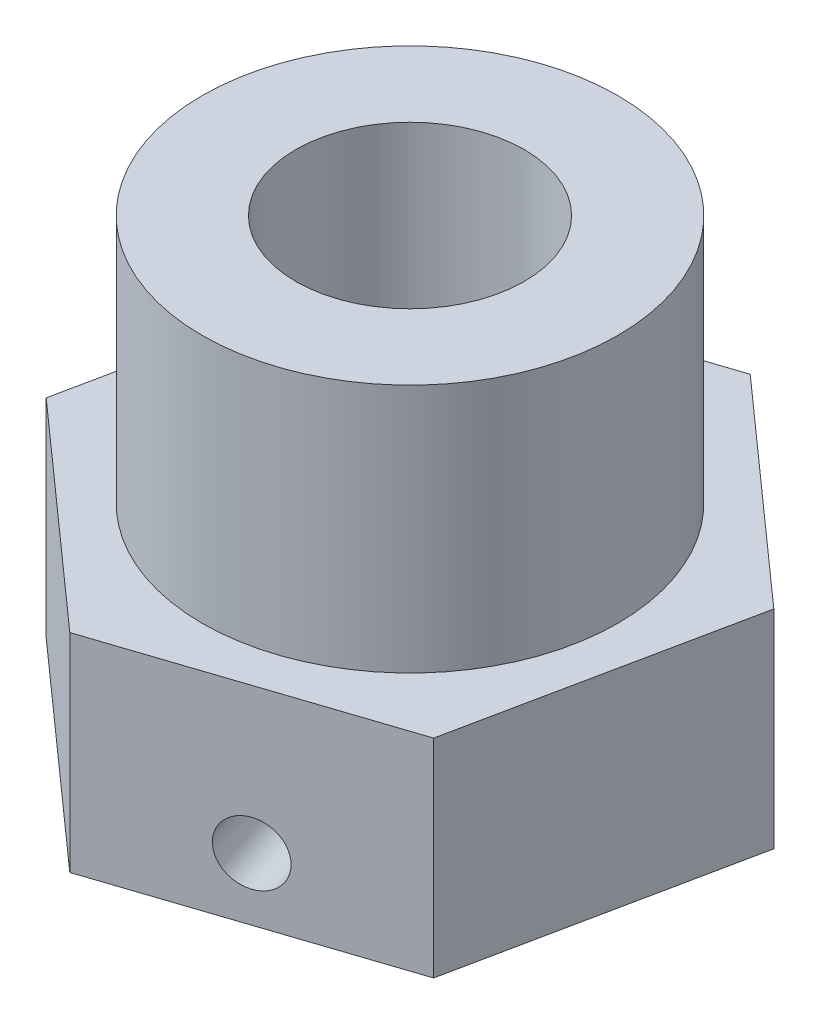
from build123d import *

# Parameters (mm, degrees)
CROQUIS1_R              = 2.75
SALIENTE_EXTRUIR1_DEPTH = 5
CROQUIS3_R              = 5
CROQUIS3_R_2            = 2.75
SALIENTE_EXTRUIR2_DEPTH = 6
CROQUIS2_R              = 0.75
CORTAR_EXTRUIR1_DEPTH   = 15.508806178


with BuildPart() as part:
    # Croquis1 → Saliente-Extruir1 (new body)
    with BuildSketch(Plane(origin=(0, 0, 0), x_dir=(1, 0, 0), z_dir=(0, 1, 0))):
        Polygon((1.401704423, 6.784926286), (-5.175066315, 4.606374782), (-6.576770738, -2.178551504), (-1.401704423, -6.784926286), (5.175066315, -4.606374782), (6.576770738, 2.178551504), align=None)
        Circle(CROQUIS1_R, mode=Mode.SUBTRACT)
    extrude(amount=SALIENTE_EXTRUIR1_DEPTH)

    # Croquis3 → Saliente-Extruir2 (add)
    with BuildSketch(Plane(origin=(0, 5, 0), x_dir=(1, 0, 0), z_dir=(0, 1, 0))):
        Circle(CROQUIS3_R)
        Circle(CROQUIS3_R_2, mode=Mode.SUBTRACT)
    extrude(amount=SALIENTE_EXTRUIR2_DEPTH)

    # Croquis2 → Cortar-Extruir1 (cut, through all)
    with BuildSketch(Plane(origin=(1.886680946, 0, 5.695650534), x_dir=(0.949275089, 0, -0.314446824), z_dir=(0.314446824, 0, 0.949275089))):
        with Locations((0, 1.5)):
            Circle(CROQUIS2_R)
    extrude(amount=-CORTAR_EXTRUIR1_DEPTH, mode=Mode.SUBTRACT)


solid = part.part
